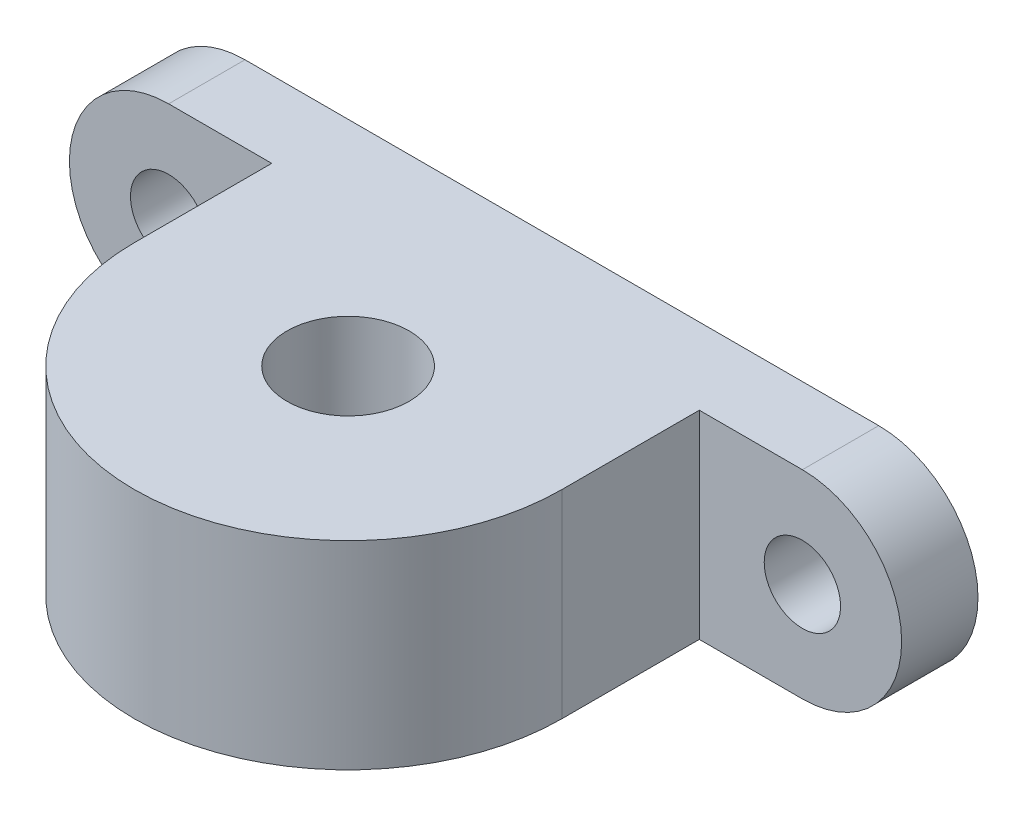
from build123d import *

# Parameters (mm, degrees)
SKETCH_1_R      = 2.5
EXTRUDE_1_DEPTH = 5
SKETCH_2_R      = 4
EXTRUDE_2_DEPTH = 13


with BuildPart() as part:
    # 草图1 → 凸台-拉伸1 (new body)
    with BuildSketch(Plane.XY):
        with BuildLine():
            Line((-20.75, -6.5), (20.75, -6.5))
            ThreePointArc((20.75, -6.5), (27.25, 0), (20.75, 6.5))
            Line((20.75, 6.5), (-20.75, 6.5))
            ThreePointArc((-20.75, 6.5), (-27.25, 0), (-20.75, -6.5))
        make_face()
        with Locations((-20.75, 0)):
            Circle(SKETCH_1_R, mode=Mode.SUBTRACT)
        with Locations((20.75, 0)):
            Circle(SKETCH_1_R, mode=Mode.SUBTRACT)
    extrude(amount=EXTRUDE_1_DEPTH)

    # 草图2 → 凸台-拉伸2 (add)
    with BuildSketch(Plane.XZ.offset(6.5)):
        with BuildLine():
            Line((-14, 14), (-14, 5))
            Line((-14, 5), (14, 5))
            Line((14, 5), (14, 14))
            ThreePointArc((14, 14), (0, 28), (-14, 14))
        make_face()
        with Locations((0, 14)):
            Circle(SKETCH_2_R, mode=Mode.SUBTRACT)
    extrude(amount=-EXTRUDE_2_DEPTH)


solid = part.part
